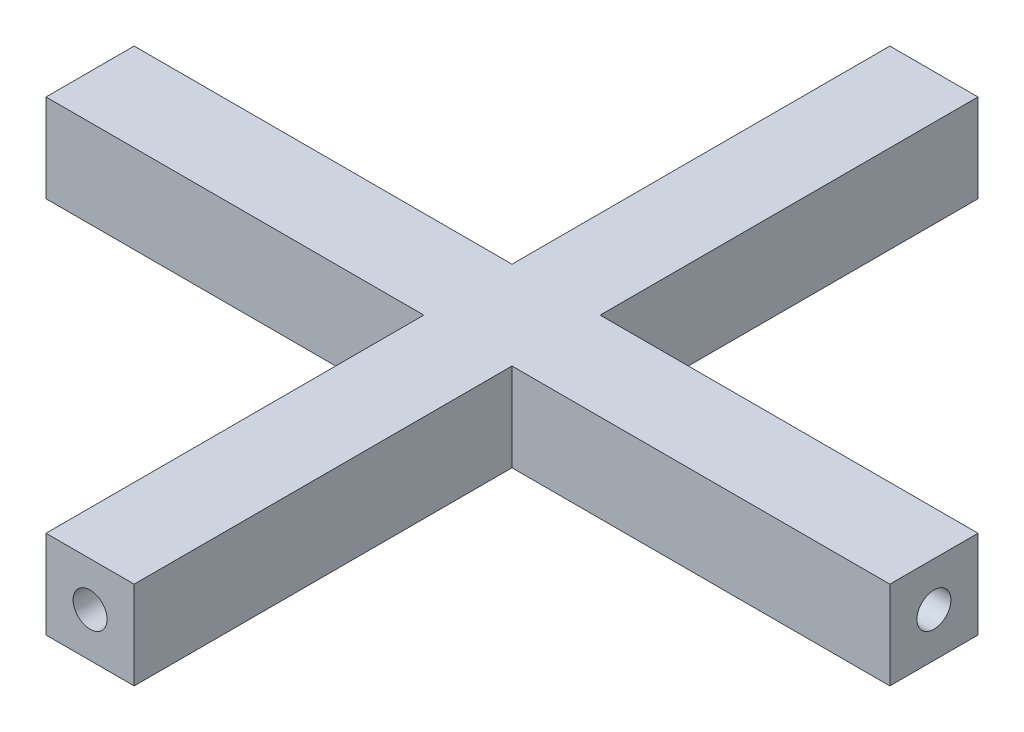
from build123d import *

# Parameters (mm, degrees)
BOSS_EXTRUDE1_DEPTH = 1.75
CUT_EXTRUDE4_START  = -1.75
SKETCH2_R           = 0.675
CUT_EXTRUDE4_DEPTH  = 16
CUT_EXTRUDE5_START  = 1.75
SKETCH2_2_R         = 0.675
CUT_EXTRUDE5_DEPTH  = 16
CUT_EXTRUDE6_START  = 1.75
SKETCH3_R           = 0.675
CUT_EXTRUDE6_DEPTH  = 16
CUT_EXTRUDE7_START  = -1.75
SKETCH3_2_R         = 0.675
CUT_EXTRUDE7_DEPTH  = 16


with BuildPart() as part:
    # Sketch1 → Boss-Extrude1 (new body, symmetric)
    with BuildSketch(Plane(origin=(0, 0, 0), x_dir=(1, 0, 0), z_dir=(0, 1, 0))):
        Polygon((1.75, -1.75), (1.75, -16.75), (-1.75, -16.75), (-1.75, -1.75), (-16.75, -1.75), (-16.75, 1.75), (-1.75, 1.75), (-1.75, 16.75), (1.75, 16.75), (1.75, 1.75), (16.75, 1.75), (16.75, -1.75), align=None)
    extrude(amount=BOSS_EXTRUDE1_DEPTH, both=True)

    # Sketch2 → Cut-Extrude4 (cut, through all)
    with BuildSketch(Plane.XY.offset(CUT_EXTRUDE4_START)):
        Circle(SKETCH2_R)
    extrude(amount=-CUT_EXTRUDE4_DEPTH, mode=Mode.SUBTRACT)

    # Sketch2_2 → Cut-Extrude5 (cut, through all)
    with BuildSketch(Plane.XY.offset(CUT_EXTRUDE5_START)):
        Circle(SKETCH2_2_R)
    extrude(amount=CUT_EXTRUDE5_DEPTH, mode=Mode.SUBTRACT)

    # Sketch3 → Cut-Extrude6 (cut, through all)
    with BuildSketch(Plane.ZY.offset(CUT_EXTRUDE6_START)):
        Circle(SKETCH3_R)
    extrude(amount=CUT_EXTRUDE6_DEPTH, mode=Mode.SUBTRACT)

    # Sketch3_2 → Cut-Extrude7 (cut, through all)
    with BuildSketch(Plane.ZY.offset(CUT_EXTRUDE7_START)):
        Circle(SKETCH3_2_R)
    extrude(amount=-CUT_EXTRUDE7_DEPTH, mode=Mode.SUBTRACT)


solid = part.part
